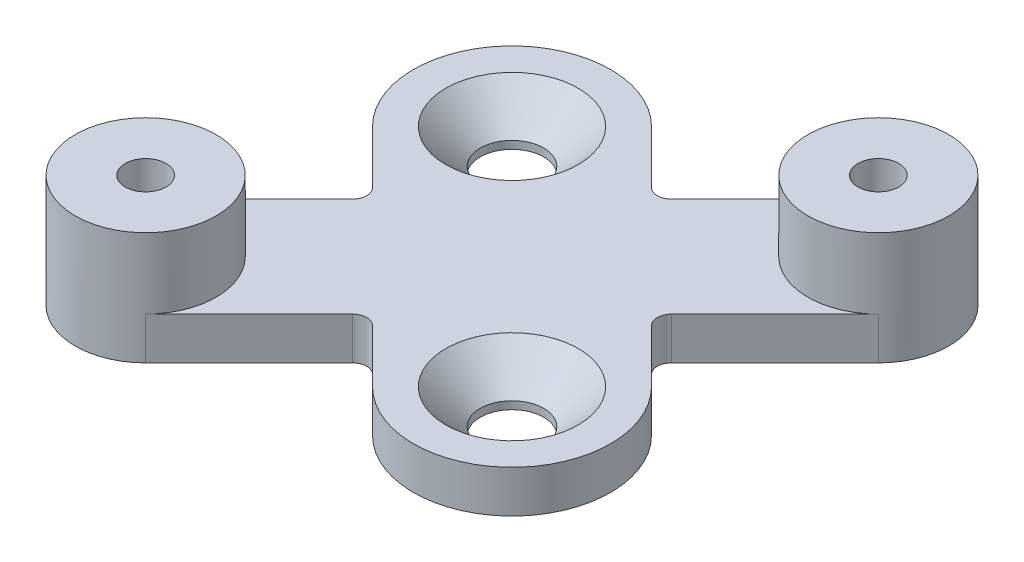
from build123d import *

# Parameters (mm, degrees)
BOSS_EXTRUDE1_DEPTH                          = 3
FILLET1_R                                    = 1
CSK_FOR_M4_COUNTERSUNK_FLAT_HEAD_SCR_2_COUNT = 2
CSK_FOR_M4_COUNTERSUNK_FLAT_HEAD_SCR_2_PITCH = 22.627416998
SKETCH4_R                                    = 5
BOSS_EXTRUDE2_DEPTH                          = 5
SKETCH5_R                                    = 1.45
CUT_EXTRUDE1_DEPTH                           = 9


with BuildPart() as part:
    # Sketch1 → Boss-Extrude1 (new body)
    with BuildSketch(Plane(origin=(0, 0, 0), x_dir=(1, 0, 0), z_dir=(0, 1, 0))):
        with BuildLine():
            Line((-16.535533906, -9.464466094), (-8.485281374, -1.414213562))
            Line((-8.485281374, -1.414213562), (-12.949747468, 3.050252532))
            ThreePointArc((-12.949747468, 3.050252532), (-12.949747468, 12.949747468), (-3.050252532, 12.949747468))
            Line((-3.050252532, 12.949747468), (1.414213562, 8.485281374))
            Line((1.414213562, 8.485281374), (9.464466094, 16.535533906))
            ThreePointArc((9.464466094, 16.535533906), (16.535533906, 16.535533906), (16.535533906, 9.464466094))
            Line((16.535533906, 9.464466094), (8.485281374, 1.414213562))
            Line((8.485281374, 1.414213562), (12.949747468, -3.050252532))
            ThreePointArc((12.949747468, -3.050252532), (12.949747468, -12.949747468), (3.050252532, -12.949747468))
            Line((3.050252532, -12.949747468), (-1.414213562, -8.485281374))
            Line((-1.414213562, -8.485281374), (-9.464466094, -16.535533906))
            ThreePointArc((-9.464466094, -16.535533906), (-16.535533906, -16.535533906), (-16.535533906, -9.464466094))
        make_face()
    extrude(amount=BOSS_EXTRUDE1_DEPTH)

    # Fillet1
    fillet1_edges = [part.edges().sort_by_distance(p)[0] for p in [
        (8.485281374, 1.5, -1.414213562),
        (-1.414213562, 1.5, 8.485281374),
        (-8.485281374, 1.5, 1.414213562),
        (1.414213562, 1.5, -8.485281374),
    ]]
    fillet(fillet1_edges, radius=FILLET1_R)

    # Sketch2 → CSK for M4 Countersunk Flat Head Screw1 (revolve, cut)
    with BuildSketch(Plane(origin=(-8, 3, -8), x_dir=(0, 0, 1), z_dir=(1, 0, 0))):
        Polygon((0, 0), (0, 3), (2.25, 3), (2.25, 2.45), (4.7, 0), align=None)
    csk_for_m4_countersunk_flat_head_screw1 = revolve(axis=Axis((-8, 9.35, -8), (0, -1, 0)), mode=Mode.SUBTRACT)

    # CSK for M4 Countersunk Flat Head Scr 2: CSK for M4 Countersunk Flat Head Screw1 ×2
    with Locations(*[Vector(0.707106781, 0, 0.707106781) * (i * CSK_FOR_M4_COUNTERSUNK_FLAT_HEAD_SCR_2_PITCH) for i in range(1, CSK_FOR_M4_COUNTERSUNK_FLAT_HEAD_SCR_2_COUNT)]):
        add(csk_for_m4_countersunk_flat_head_screw1, mode=Mode.SUBTRACT)

    # Sketch4 → Boss-Extrude2 (add)
    with BuildSketch(Plane(origin=(0, 3, 0), x_dir=(1, 0, 0), z_dir=(0, 1, 0))):
        with Locations((-13, -13)):
            Circle(SKETCH4_R)
        with Locations((13, 13)):
            Circle(SKETCH4_R)
    extrude(amount=BOSS_EXTRUDE2_DEPTH)

    # Sketch5 → Cut-Extrude1 (cut, through all)
    with BuildSketch(Plane(origin=(0, 8, 0), x_dir=(1, 0, 0), z_dir=(0, 1, 0))):
        with Locations((-13, -13)):
            Circle(SKETCH5_R)
        with Locations((13, 13)):
            Circle(SKETCH5_R)
    extrude(amount=-CUT_EXTRUDE1_DEPTH, mode=Mode.SUBTRACT)


solid = part.part
